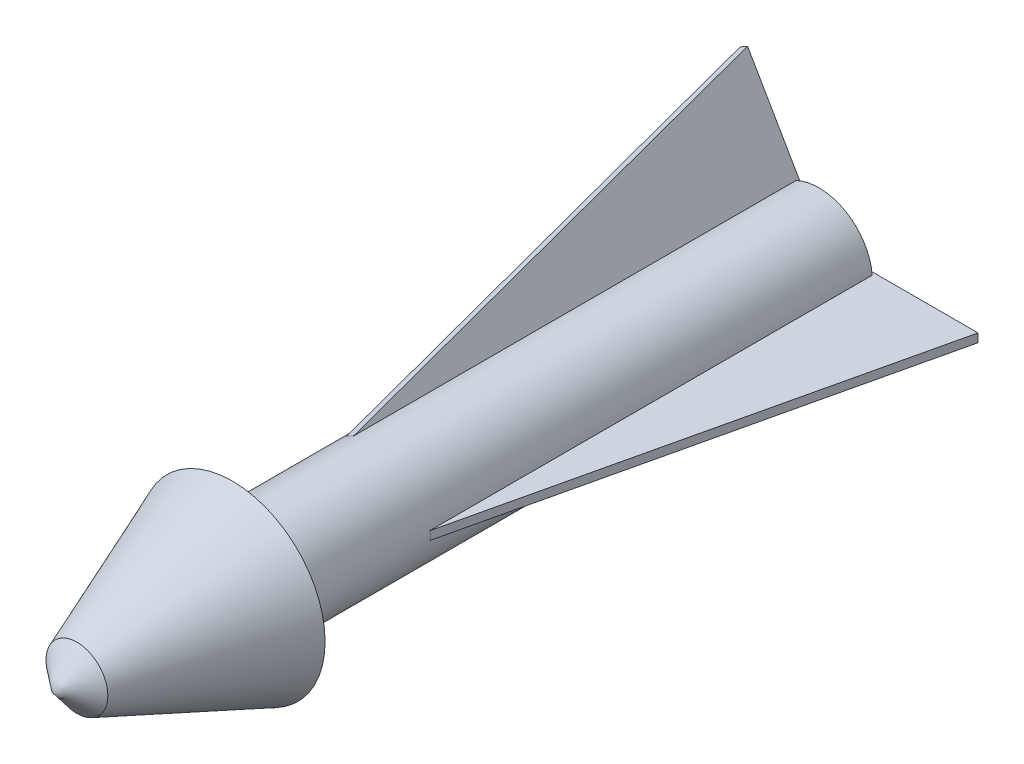
from build123d import *

# Parameters (mm, degrees)
FILLET1_R           = 3
BOSS_EXTRUDE2_DEPTH = 0.5
CIRPATTERN3_COUNT   = 3


with BuildPart() as part:
    # Sketch1 → Revolve2 (revolve)
    with BuildSketch(Plane(origin=(0, 0, 0), x_dir=(0, 0, -1), z_dir=(1, 0, 0))):
        Polygon((6.835567607, 0), (6.835567607, 4.933028396), (56.835567607, 4.933028396), (56.835567607, 6.266802226), (-11.993527317, 6.266802226), (-11.993527317, 10.876596073), (-30.238642963, 3.628152456), (-33.164432393, 0), align=None)
    revolve(axis=Axis((0, 0, 44.67851679), (0, 0, -1)))

    # Fillet1
    fillet1_edges = [part.edges().sort_by_distance(p)[0] for p in [
        (0, -6.266802226, 11.993527317),
    ]]
    fillet(fillet1_edges, radius=FILLET1_R)

    # Sketch2 → Boss-Extrude2 (add, symmetric)
    with BuildSketch(Plane(origin=(0, 0, 0), x_dir=(1, 0, 0), z_dir=(0, 1, 0))):
        Polygon((5.575190906, 1.997056238), (18.315636179, 57.181987564), (5.575190906, 57.181987564), align=None)
    boss_extrude2 = extrude(amount=BOSS_EXTRUDE2_DEPTH, both=True)

    # CirPattern3: Boss-Extrude2 ×3 about axis
    cirpattern3_axis = Axis((0, 0, -56.835567607), (0, 0, 1))
    for i in range(1, CIRPATTERN3_COUNT):
        add(boss_extrude2.rotate(cirpattern3_axis, i * 360 / CIRPATTERN3_COUNT))


solid = part.part
